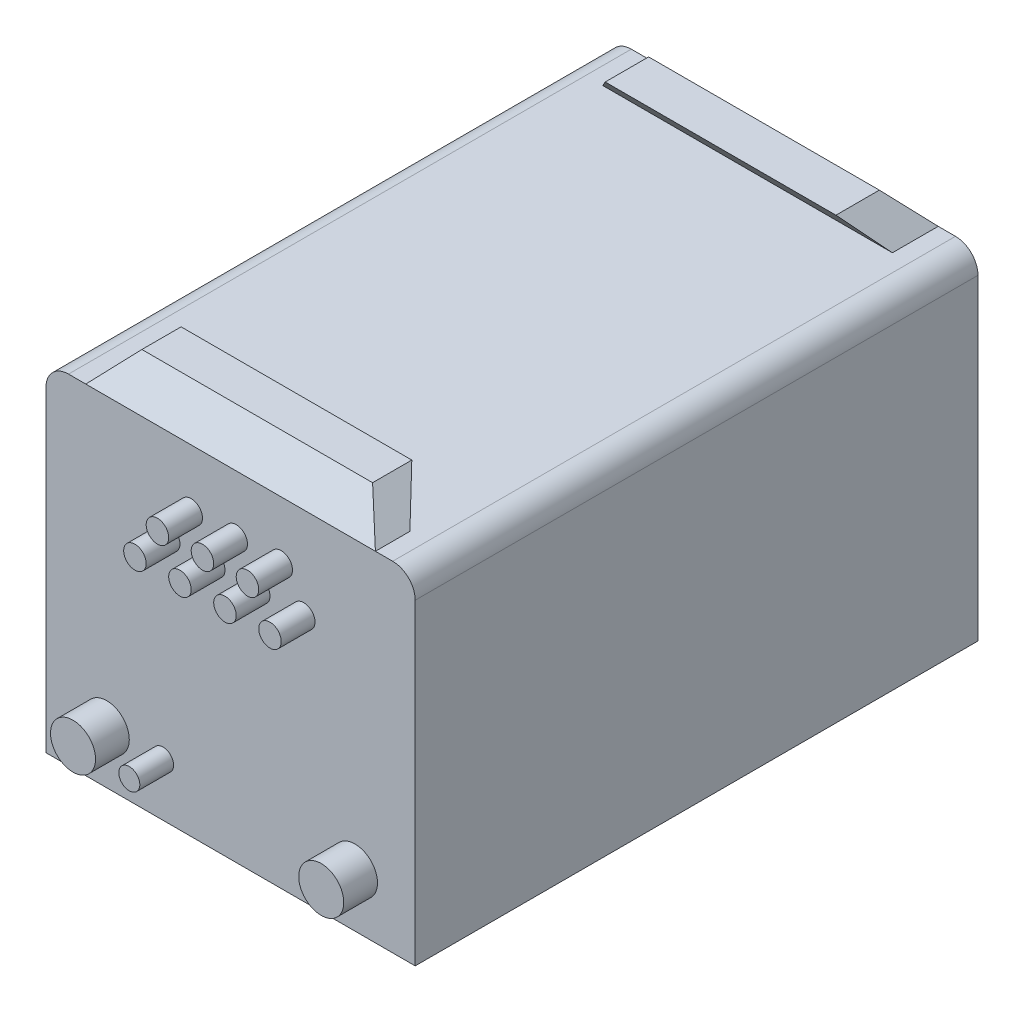
from build123d import *

# Parameters (mm, degrees)
EXTRUDE_1_DEPTH     = 500
CUT_EXTRUDE_1_DEPTH = 165
SKETCH_4_R          = 20
SKETCH_4_R_2        = 9.341042427
SKETCH_4_R_3        = 10
EXTRUDE_2_DEPTH     = 30
SKETCH_5_R          = 8.254931616
SKETCH_5_R_2        = 9.226679221
EXTRUDE_3_DEPTH     = 30


with BuildPart() as part:
    # Эскиз2 → Бобышка-Вытянуть1 (new body)
    with BuildSketch(Plane.XY):
        with BuildLine():
            Line((-164, 0), (164, 0))
            Line((164, 0), (164, 281.346442364))
            ThreePointArc((164, 281.346442364), (158.142135624, 295.488577987), (144, 301.346442364))
            Line((144, 301.346442364), (128.648418925, 301.346442364))
            Line((128.648418925, 301.346442364), (102.483646542, 329.199264578))
            Line((102.483646542, 329.199264578), (-102.483646542, 329.199264578))
            Line((-102.483646542, 329.199264578), (-128.648418925, 301.346442364))
            Line((-128.648418925, 301.346442364), (-144, 301.346442364))
            ThreePointArc((-144, 301.346442364), (-158.142135624, 295.488577987), (-164, 281.346442364))
            Line((-164, 281.346442364), (-164, 0))
        make_face()
    extrude(amount=EXTRUDE_1_DEPTH)

    # Эскиз3 → Вырез-Вытянуть1 (cut, symmetric)
    with BuildSketch(Plane(origin=(0, 0, 0), x_dir=(0, 0, -1), z_dir=(1, 0, 0))):
        Polygon((-463.138471818, 344.733431976), (-500, 301.346442364), (-514.613262102, 301.346442364), (-514.613262102, 363.370856045), (0, 363.370856045), (0, 301.346442364), (-40.69019293, 344.733431976), (-73.527559146, 339.458620278), (-40.69019293, 301.346442364), (-469.350946507, 301.346442364), (-431.238768593, 339.458620278), align=None)
    extrude(amount=CUT_EXTRUDE_1_DEPTH, both=True, mode=Mode.SUBTRACT)

    # Эскиз4 → Бобышка-Вытянуть2 (add)
    with BuildSketch(Plane.XY.offset(500)):
        with Locations((-110, 47.069313646)):
            Circle(SKETCH_4_R)
        with Locations((-60, 47.069313646)):
            Circle(SKETCH_4_R_2)
        with Locations((110.509329497, 47.069313646)):
            Circle(SKETCH_4_R)
        with Locations((-35, 250)):
            Circle(SKETCH_4_R_3)
        with Locations((-55, 220)):
            Circle(SKETCH_4_R_3)
        with Locations((-15, 220)):
            Circle(SKETCH_4_R_3)
        with Locations((25, 220)):
            Circle(SKETCH_4_R_3)
        with Locations((65, 220)):
            Circle(SKETCH_4_R_3)
        with Locations((5, 250)):
            Circle(SKETCH_4_R_3)
        with Locations((45, 250)):
            Circle(SKETCH_4_R_3)
    extrude(amount=EXTRUDE_2_DEPTH)

    # Эскиз5 → Бобышка-Вытянуть3 (add)
    with BuildSketch(Plane(origin=(0, 0, 0), x_dir=(-1, 0, 0), z_dir=(0, 0, -1))):
        with Locations((-12.302238961, 29.934052236)):
            Circle(SKETCH_5_R)
        with Locations((-73.813433765, 29.934052236)):
            Circle(SKETCH_5_R_2)
    extrude(amount=EXTRUDE_3_DEPTH)


solid = part.part
